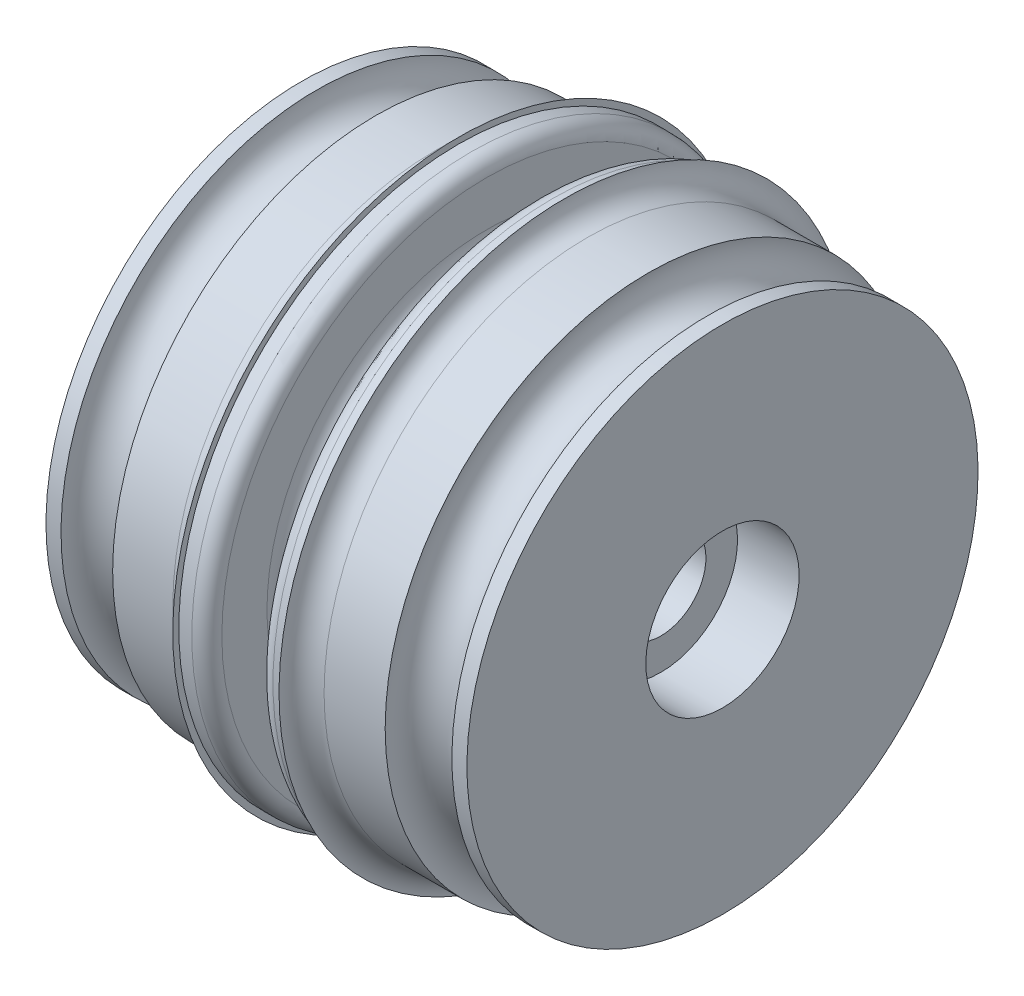
from build123d import *


with BuildPart() as part:
    # 草图1 → 旋转1 (revolve)
    with BuildSketch(Plane.XY):
        with BuildLine():
            Line((17.800391272, 19), (17.800391272, 18.6))
            Line((17.800391272, 18.6), (17.000391272, 18.6))
            ThreePointArc((17.000391272, 18.6), (16.293284491, 18.307106781), (16.000391272, 17.6))
            Line((16.000391272, 17.6), (16.000391272, 14.6))
            ThreePointArc((16.000391272, 14.6), (15.561051444, 13.539339828), (14.500391272, 13.1))
            Line((14.500391272, 13.1), (14.100391272, 13.1))
            ThreePointArc((14.100391272, 13.1), (13.0397311, 13.539339828), (12.600391272, 14.6))
            Line((12.600391272, 14.6), (12.600391272, 17.6))
            ThreePointArc((12.600391272, 17.6), (12.307498053, 18.307106781), (11.600391272, 18.6))
            Line((11.600391272, 18.6), (10.736882945, 18.6))
            Line((10.736882945, 18.6), (10.736882945, 19))
            ThreePointArc((10.736882945, 19), (10.297543117, 17.939339828), (9.236882945, 17.5))
            Line((9.236882945, 17.5), (5.236882945, 17.5))
            ThreePointArc((5.236882945, 17.5), (3.552399857, 15.015940607), (1.300391272, 17))
            Line((1.300391272, 17), (0.300391272, 17))
            Line((0.300391272, 17), (0.300391272, 5.1))
            Line((0.300391272, 5.1), (4.400391272, 5.1))
            Line((4.400391272, 5.1), (4.400391272, 3))
            Line((4.400391272, 3), (24.200391272, 3))
            Line((24.200391272, 3), (24.200391272, 5.1))
            Line((24.200391272, 5.1), (28.300391272, 5.1))
            Line((28.300391272, 5.1), (28.300391272, 17))
            Line((28.300391272, 17), (27.300391272, 17))
            ThreePointArc((27.300391272, 17), (25.048382687, 15.015940607), (23.363899599, 17.5))
            Line((23.363899599, 17.5), (19.300391272, 17.5))
            ThreePointArc((19.300391272, 17.5), (18.2397311, 17.939339828), (17.800391272, 19))
        make_face()
    revolve(axis=Axis((0, 0, 0), (1, 0, 0)))


solid = part.part
